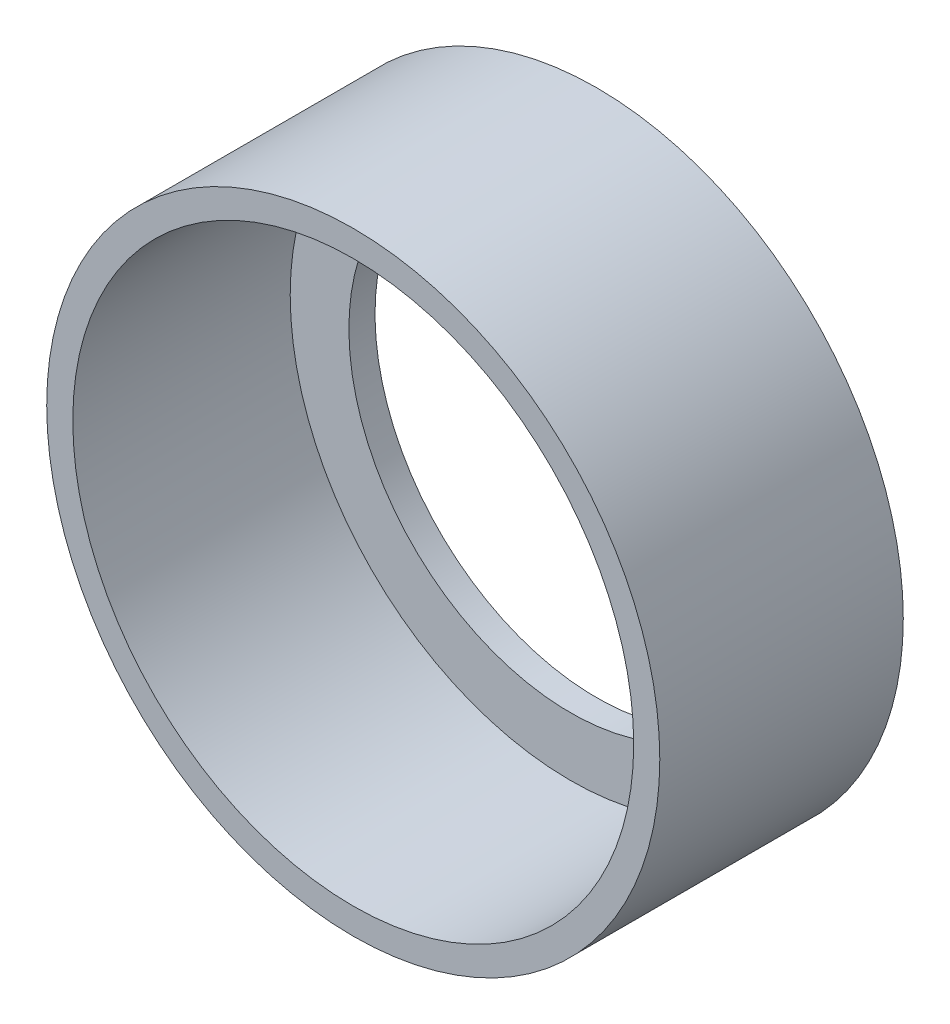
from build123d import *

# Parameters (mm, degrees)
CUT_EXTRUDE1_DEPTH = 15.224


with BuildPart() as part:
    # Sketch1 → Revolve1 (revolve)
    with BuildSketch(Plane(origin=(0, 0, 0), x_dir=(1, 0, 0), z_dir=(0, 1, 0))):
        Polygon((16.383, 5.425637802), (17.907, 5.425637802), (17.907, 19.649637802), (12.954, 19.649637802), (12.954, 18.125637802), (16.383, 18.125637802), align=None)
    revolve(axis=Axis((0, 0, -10.179008168), (0, 0, 1)))

    # Sketch2 → Cut-Extrude1 (cut, through all)
    with BuildSketch(Plane(origin=(0, 0, -19.649637802), x_dir=(-1, 0, 0), z_dir=(0, 0, -1))):
        with BuildLine():
            Line((-4.8895, 15.636351197), (-4.8895, 10.556351197))
            Line((-4.8895, 10.556351197), (4.8895, 10.556351197))
            Line((4.8895, 10.556351197), (4.8895, 15.636351197))
            ThreePointArc((4.8895, 15.636351197), (0, 16.383), (-4.8895, 15.636351197))
        make_face()
    extrude(amount=-CUT_EXTRUDE1_DEPTH, mode=Mode.SUBTRACT)


solid = part.part
